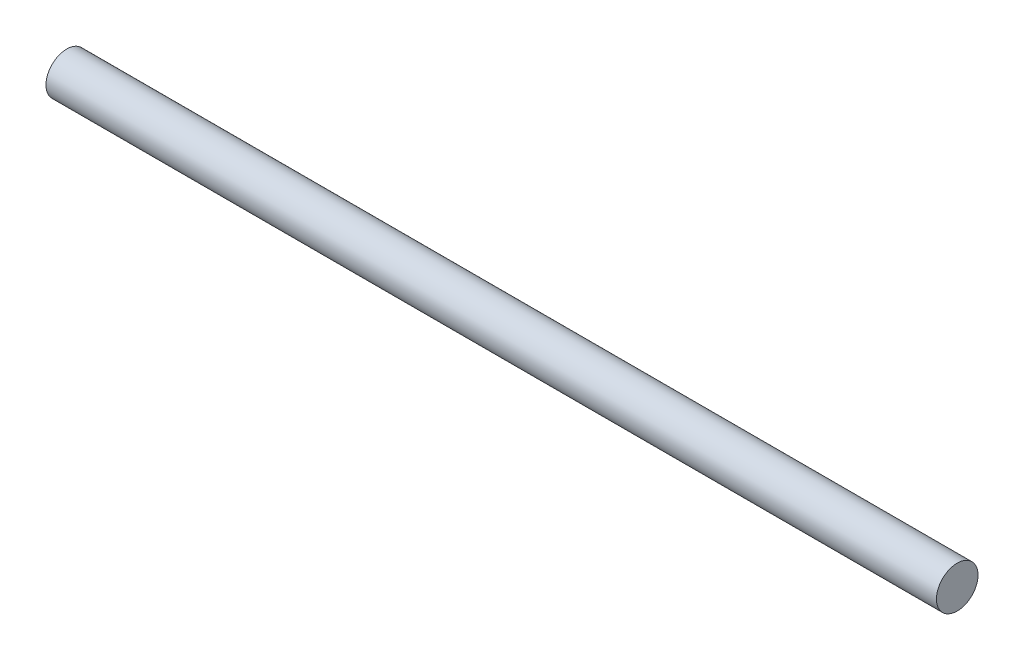
from build123d import *

# Parameters (mm, degrees)
SKETCH_1_R      = 14
EXTRUDE_1_DEPTH = 600


with BuildPart() as part:
    # Эскиз1 → Бобышка-Вытянуть1 (new body)
    with BuildSketch(Plane(origin=(0, 0, 0), x_dir=(0, 0, -1), z_dir=(1, 0, 0))):
        Circle(SKETCH_1_R)
    extrude(amount=EXTRUDE_1_DEPTH)


solid = part.part
